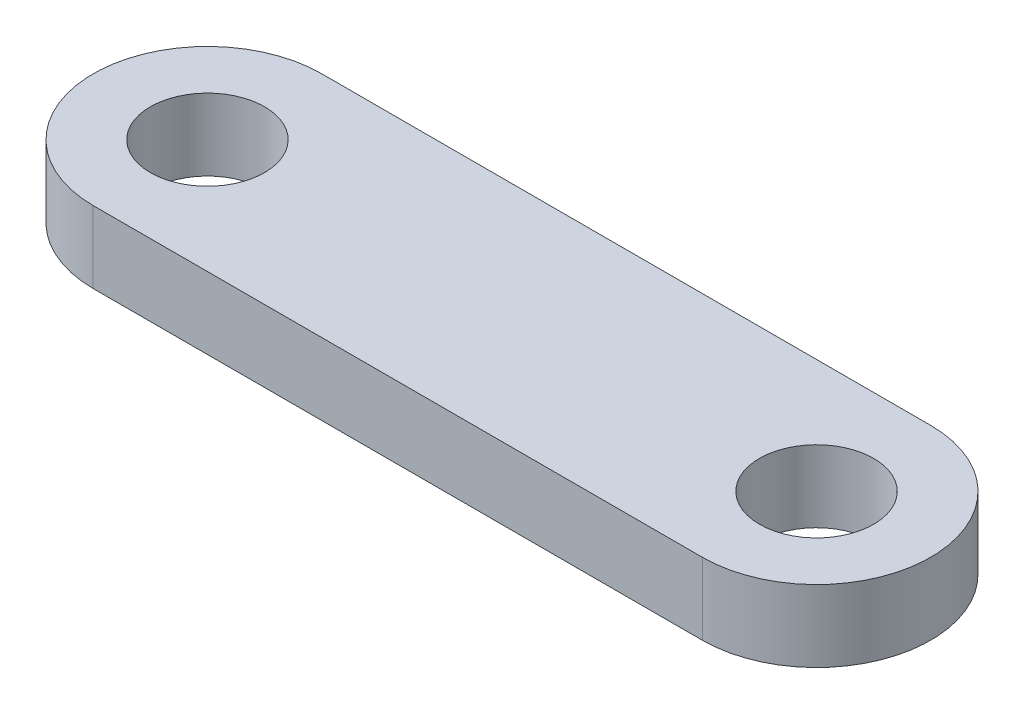
from build123d import *

# Parameters (mm, degrees)
SKETCH1_R      = 2.38125
EXTRUDE1_DEPTH = 1.4986


with BuildPart() as part:
    # Sketch1 → Extrude1 (new body, symmetric)
    with BuildSketch(Plane(origin=(0, 0, 0), x_dir=(1, 0, 0), z_dir=(0, 1, 0))):
        with BuildLine():
            Line((-12.7, 4.7625), (12.7, 4.7625))
            ThreePointArc((12.7, 4.7625), (17.4625, 0), (12.7, -4.7625))
            Line((12.7, -4.7625), (-12.7, -4.7625))
            ThreePointArc((-12.7, -4.7625), (-17.4625, 0), (-12.7, 4.7625))
        make_face()
        with Locations(Location((-12.7, 0, 0), (0, 0, 270))):  # turned: the seam where the file's is
            Circle(SKETCH1_R, mode=Mode.SUBTRACT)
        with Locations(Location((12.7, 0, 0), (0, 0, 270))):  # turned: the seam where the file's is
            Circle(SKETCH1_R, mode=Mode.SUBTRACT)
    extrude(amount=EXTRUDE1_DEPTH, both=True)


solid = part.part
